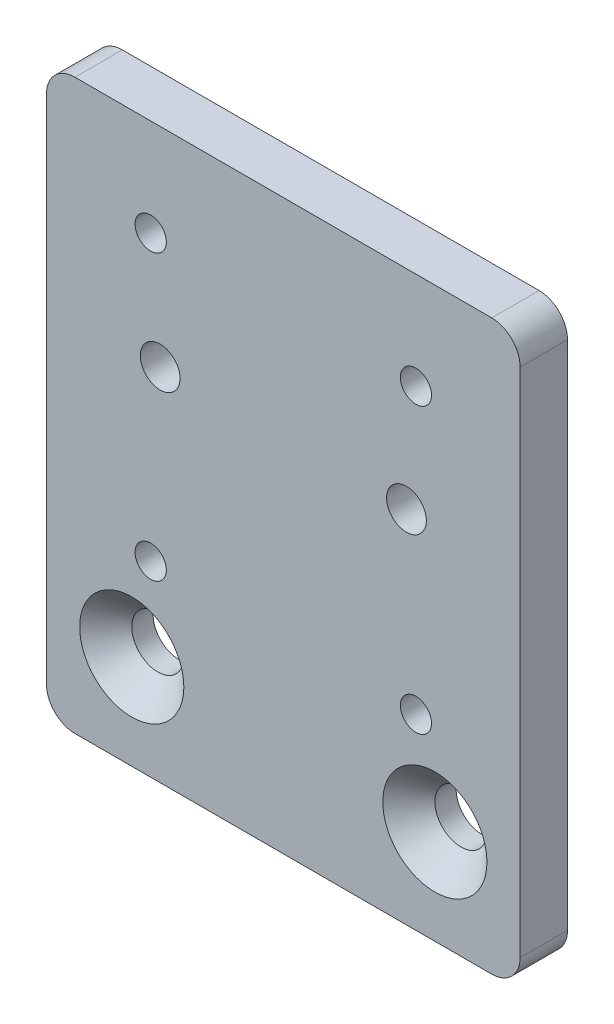
from build123d import *

# Parameters (mm, degrees)
SKIZZE1_W                                            = 50
SKIZZE1_H                                            = 60
AUFSATZ_LINEAR_AUSTRAGEN1_DEPTH                      = 5
FORMSENKUNG_F_R_M5_LINSENSENKSCHRAUBE_MI_D           = 5.5
FORMSENKUNG_F_R_M5_LINSENSENKSCHRAUBE_MI_DEPTH       = 20
FORMSENKUNG_F_R_M5_LINSENSENKSCHRAUBE_MI_CSINK_D     = 11
FORMSENKUNG_F_R_M5_LINSENSENKSCHRAUBE_MI_CSINK_ANGLE = 90
FORMSENKUNG_F_R_M5_LINSENSENKSCHRAUBE_MI_TIP         = 1.652366702
KERNLOCH_F_R_M4_GEWINDE1_D                           = 3.3
KERNLOCH_F_R_M5_GEWINDE1_D                           = 4.2
VERRUNDUNG1_R                                        = 3


with BuildPart() as part:
    # Skizze1 → Aufsatz-Linear austragen1 (new body)
    with BuildSketch(Plane.XY):
        with Locations((0, 30)):
            Rectangle(SKIZZE1_W, SKIZZE1_H)
    extrude(amount=-AUFSATZ_LINEAR_AUSTRAGEN1_DEPTH)

    # Formsenkung für M5 Linsensenkschraube mit Schlitz1
    with Locations(Plane.XY):
        with Locations((-16, 10), (16, 10)):
            CounterSinkHole(FORMSENKUNG_F_R_M5_LINSENSENKSCHRAUBE_MI_D / 2, FORMSENKUNG_F_R_M5_LINSENSENKSCHRAUBE_MI_CSINK_D / 2, depth=FORMSENKUNG_F_R_M5_LINSENSENKSCHRAUBE_MI_DEPTH, counter_sink_angle=FORMSENKUNG_F_R_M5_LINSENSENKSCHRAUBE_MI_CSINK_ANGLE)
            with Locations((0, 0, -(FORMSENKUNG_F_R_M5_LINSENSENKSCHRAUBE_MI_DEPTH + FORMSENKUNG_F_R_M5_LINSENSENKSCHRAUBE_MI_TIP / 2))):  # 118° drill point
                Cone(0, FORMSENKUNG_F_R_M5_LINSENSENKSCHRAUBE_MI_D / 2, FORMSENKUNG_F_R_M5_LINSENSENKSCHRAUBE_MI_TIP, mode=Mode.SUBTRACT)

    # Kernloch für M4 Gewinde1 (through all)
    with Locations(Plane.XY):
        with Locations((-14, 19.75), (14, 19.75), (-14, 49.75), (14, 49.75)):
            Hole(KERNLOCH_F_R_M4_GEWINDE1_D / 2)

    # Kernloch für M5 Gewinde1 (through all)
    with Locations(Plane.XY):
        with Locations((-13, 38), (13, 38)):
            Hole(KERNLOCH_F_R_M5_GEWINDE1_D / 2)

    # Verrundung1
    verrundung1_edges = [part.edges().sort_by_distance(p)[0] for p in [
        (25, 0, -2.5),
        (-25, 0, -2.5),
        (-25, 60, -2.5),
        (25, 60, -2.5),
    ]]
    fillet(verrundung1_edges, radius=VERRUNDUNG1_R)


solid = part.part
